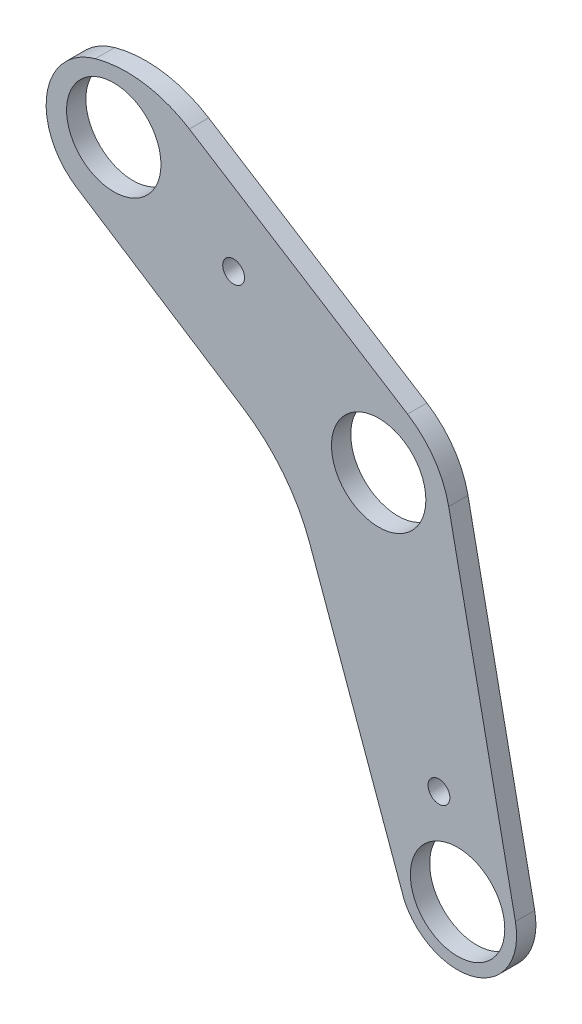
from build123d import *

# Parameters (mm, degrees)
SKETCH1_R           = 14.2875
SKETCH1_R_2         = 3.302
BOSS_EXTRUDE1_DEPTH = 5.842
FILLET6_R           = 35.56
FILLET10_R          = 27.94
FILLET13_R          = 50.8
FILLET16_R          = 20.32


with BuildPart() as part:
    # Sketch1 → Boss-Extrude1 (new body)
    with BuildSketch(Plane(origin=(0, 0, 0), x_dir=(-1, 0, 0), z_dir=(0, 0, -1))):
        with BuildLine():
            Line((165.785053206, 142.946766421), (130.990896358, 174.574150067))
            Line((130.990896358, 174.574150067), (31.981087973, 112.057039535))
            Line((31.981087973, 112.057039535), (9.409224511, 1.710371233))
            ThreePointArc((9.409224511, 1.710371233), (21.197749586, -18.801775256), (43.01064713, -9.641263383))
            Line((43.01064713, -9.641263383), (77.484953862, 85.860414024))
            Line((77.484953862, 85.860414024), (165.785053206, 142.946766421))
        make_face()
        with Locations((130.990896358, 146.510317071)):
            Circle(SKETCH1_R, mode=Mode.SUBTRACT)
        with Locations((32.554001794, 24.213373462)):
            Circle(SKETCH1_R_2, mode=Mode.SUBTRACT)
        with Locations((94.707078764, 129.476886965)):
            Circle(SKETCH1_R_2, mode=Mode.SUBTRACT)
        with Locations((50.8, 98.679)):
            Circle(SKETCH1_R, mode=Mode.SUBTRACT)
        with Locations((26.917500437, -1.871018398)):
            Circle(SKETCH1_R, mode=Mode.SUBTRACT)
    extrude(amount=-BOSS_EXTRUDE1_DEPTH)

    # Fillet6
    fillet6_edges = [part.edges().sort_by_distance(p)[0] for p in [
        (-130.990896358, 174.574150067, 2.921),
    ]]
    fillet(fillet6_edges, radius=FILLET6_R)

    # Fillet10
    fillet10_edges = [part.edges().sort_by_distance(p)[0] for p in [
        (-31.981087973, 112.057039535, 2.921),
    ]]
    fillet(fillet10_edges, radius=FILLET10_R)

    # Fillet13
    fillet13_edges = [part.edges().sort_by_distance(p)[0] for p in [
        (-77.484953862, 85.860414024, 2.921),
    ]]
    fillet(fillet13_edges, radius=FILLET13_R)

    # Fillet16
    fillet16_edges = [part.edges().sort_by_distance(p)[0] for p in [
        (-165.785053206, 142.946766421, 2.921),
    ]]
    fillet(fillet16_edges, radius=FILLET16_R)


solid = part.part
